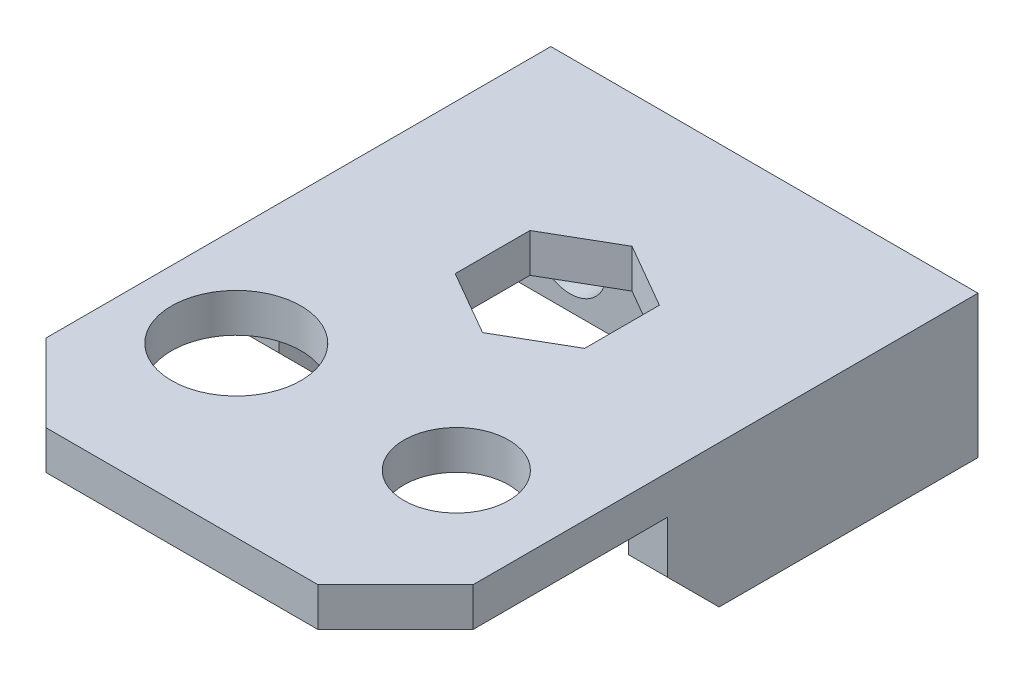
from build123d import *

# Parameters (mm, degrees)
CROQUIS1_R              = 5
CROQUIS1_R_2            = 4.05
SALIENTE_EXTRUIR1_DEPTH = 3
CROQUIS5_W              = 3
CROQUIS5_H              = 21
SALIENTE_EXTRUIR3_DEPTH = 8
CROQUIS11_W             = 3
CROQUIS11_H             = 21
SALIENTE_EXTRUIR6_DEPTH = 8
CORTAR_EXTRUIR3_DEPTH   = 34
CORTAR_EXTRUIR4_DEPTH   = 3
SALIENTE_EXTRUIR8_DEPTH = 8
CROQUIS15_R             = 1.55
CORTAR_EXTRUIR6_DEPTH   = 7
CROQUIS16_R             = 2.8
CROQUIS16_R_2           = 1.55
CORTAR_EXTRUIR7_DEPTH   = 3


with BuildPart() as part:
    # Croquis1 → Saliente-Extruir1 (new body)
    with BuildSketch(Plane(origin=(0, 0, 0), x_dir=(1, 0, 0), z_dir=(0, 1, 0))):
        Polygon((0, 32), (25.301087099, 32), (25.301087099, -7), (19.301087099, -13), (-1.698912901, -13), (-7.698912901, -7), (-7.698912901, 32), align=None)
        Circle(CROQUIS1_R, mode=Mode.SUBTRACT)
        with Locations((17, 0)):
            Circle(CROQUIS1_R_2, mode=Mode.SUBTRACT)
    extrude(amount=SALIENTE_EXTRUIR1_DEPTH)

    # Croquis5 → Saliente-Extruir3 (add)
    with BuildSketch(Plane.XZ):
        with Locations((-6.198912901, -18.5)):
            Rectangle(CROQUIS5_W, CROQUIS5_H)
    extrude(amount=SALIENTE_EXTRUIR3_DEPTH)

    # Croquis11 → Saliente-Extruir6 (add)
    with BuildSketch(Plane.XZ):
        with Locations((23.801087099, -18.5)):
            Rectangle(CROQUIS11_W, CROQUIS11_H)
    extrude(amount=SALIENTE_EXTRUIR6_DEPTH)

    # Croquis7 → Cortar-Extruir3 (cut, through all)
    with BuildSketch(Plane.ZY.offset(7.698912901)):
        Polygon((-8, -8), (-12, -8), (-8, -4), align=None)
    extrude(amount=-CORTAR_EXTRUIR3_DEPTH, mode=Mode.SUBTRACT)

    # Croquis9 → Cortar-Extruir4 (cut)
    with BuildSketch(Plane(origin=(0, 3, 0), x_dir=(1, 0, 0), z_dir=(0, 1, 0))):
        Polygon((8.801087099, 10.226497308), (13.801087099, 13.113248654), (13.801087099, 18.886751346), (8.801087099, 21.773502692), (3.801087099, 18.886751346), (3.801087099, 13.113248654), align=None)
    extrude(amount=-CORTAR_EXTRUIR4_DEPTH, mode=Mode.SUBTRACT)

    # Croquis13 → Saliente-Extruir8 (add)
    with BuildSketch(Plane.XZ):
        Polygon((-4.698912901, -29), (-4.698912901, -26), (22.301087099, -26), (22.301087099, -29), (25.301087099, -29), (25.301087099, -32), (-7.698912901, -32), (-7.698912901, -29), align=None)
    extrude(amount=SALIENTE_EXTRUIR8_DEPTH)

    # Croquis15 → Cortar-Extruir6 (cut, through all)
    with BuildSketch(Plane.XY.offset(-26)):
        with Locations((-0.198912901, -4)):
            Circle(CROQUIS15_R)
        with Locations((17.801087099, -4)):
            Circle(CROQUIS15_R)
    extrude(amount=-CORTAR_EXTRUIR6_DEPTH, mode=Mode.SUBTRACT)

    # Croquis16 → Cortar-Extruir7 (cut)
    with BuildSketch(Plane.XY.offset(-26)):
        with Locations((-0.198912901, -4)):
            Circle(CROQUIS16_R)
        with Locations((-0.198912901, -4)):
            Circle(CROQUIS16_R_2, mode=Mode.SUBTRACT)
        with Locations((17.801087099, -4)):
            Circle(CROQUIS16_R)
        with Locations((17.801087099, -4)):
            Circle(CROQUIS16_R_2, mode=Mode.SUBTRACT)
    extrude(amount=-CORTAR_EXTRUIR7_DEPTH, mode=Mode.SUBTRACT)


solid = part.part
